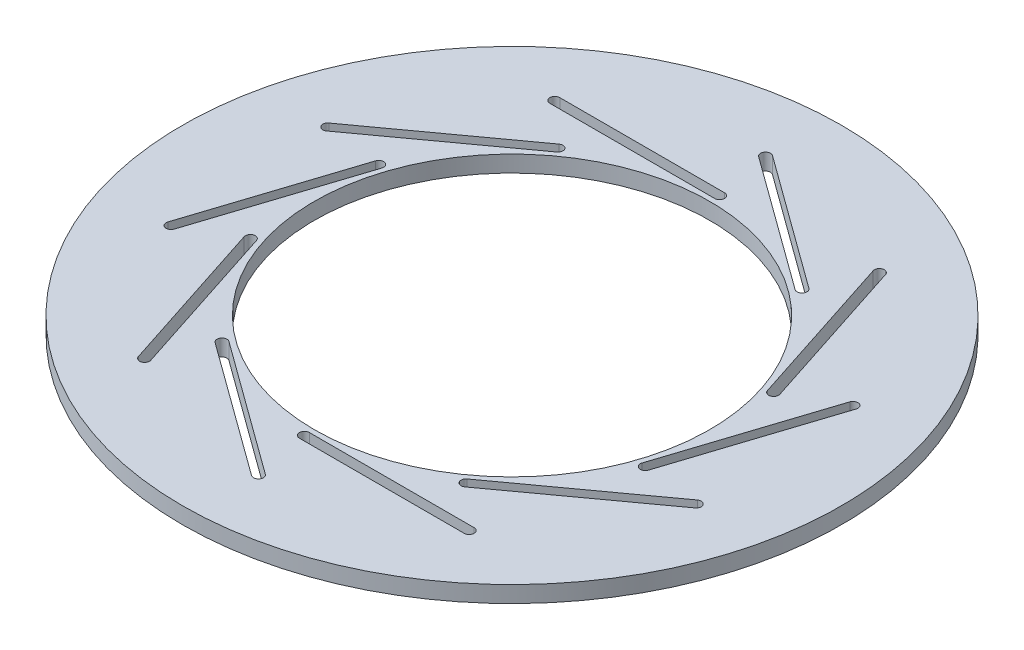
from build123d import *

# Parameters (mm, degrees)
SKETCH1_R           = 100
SKETCH1_R_2         = 60
BOSS_EXTRUDE1_DEPTH = 5


with BuildPart() as part:
    # Sketch1 → Boss-Extrude1 (new body)
    with BuildSketch(Plane(origin=(0, 0, 0), x_dir=(1, 0, 0), z_dir=(0, 1, 0))):
        Circle(SKETCH1_R)
        Circle(SKETCH1_R_2, mode=Mode.SUBTRACT)
        with BuildLine():
            Line((0, 61.5), (-50, 61.5))
            ThreePointArc((-50, 61.5), (-51.5, 63), (-50, 64.5))
            Line((-50, 64.5), (0, 64.5))
            ThreePointArc((0, 64.5), (1.5, 63), (0, 61.5))
        make_face(mode=Mode.SUBTRACT)
        with BuildLine():
            Line((36.148793016, 49.754545154), (-4.302056703, 79.143807769))
            ThreePointArc((-4.302056703, 79.143807769), (-4.633904316, 81.239011139), (-2.538700946, 81.570858752))
            Line((-2.538700946, 81.570858752), (37.912148773, 52.181596137))
            ThreePointArc((37.912148773, 52.181596137), (38.243996386, 50.086392767), (36.148793016, 49.754545154))
        make_face(mode=Mode.SUBTRACT)
        with BuildLine():
            Line((58.489975752, 19.004545154), (43.039126033, 66.557370969))
            ThreePointArc((43.039126033, 66.557370969), (44.002185316, 68.447481235), (45.892295582, 67.484421952))
            Line((45.892295582, 67.484421952), (61.343145301, 19.931596137))
            ThreePointArc((61.343145301, 19.931596137), (60.380086018, 18.041485871), (58.489975752, 19.004545154))
        make_face(mode=Mode.SUBTRACT)
        with BuildLine():
            Line((58.489975752, -19.004545154), (73.940825471, 28.548280661))
            ThreePointArc((73.940825471, 28.548280661), (75.830935737, 29.511339944), (76.79399502, 27.621229678))
            Line((76.79399502, 27.621229678), (61.343145301, -19.931596137))
            ThreePointArc((61.343145301, -19.931596137), (59.453035035, -20.89465542), (58.489975752, -19.004545154))
        make_face(mode=Mode.SUBTRACT)
        with BuildLine():
            Line((36.148793016, -49.754545154), (76.599642735, -20.365282539))
            ThreePointArc((76.599642735, -20.365282539), (78.694846105, -20.697130153), (78.362998492, -22.792333523))
            Line((78.362998492, -22.792333523), (37.912148773, -52.181596137))
            ThreePointArc((37.912148773, -52.181596137), (35.816945403, -51.849748524), (36.148793016, -49.754545154))
        make_face(mode=Mode.SUBTRACT)
        with BuildLine():
            Line((0, -61.5), (50, -61.5))
            ThreePointArc((50, -61.5), (51.5, -63), (50, -64.5))
            Line((50, -64.5), (0, -64.5))
            ThreePointArc((0, -64.5), (-1.5, -63), (0, -61.5))
        make_face(mode=Mode.SUBTRACT)
        with BuildLine():
            Line((-36.148793016, -49.754545154), (4.302056703, -79.143807769))
            ThreePointArc((4.302056703, -79.143807769), (4.633904316, -81.239011139), (2.538700946, -81.570858752))
            Line((2.538700946, -81.570858752), (-37.912148773, -52.181596137))
            ThreePointArc((-37.912148773, -52.181596137), (-38.243996386, -50.086392767), (-36.148793016, -49.754545154))
        make_face(mode=Mode.SUBTRACT)
        with BuildLine():
            Line((-58.489975752, -19.004545154), (-43.039126033, -66.557370969))
            ThreePointArc((-43.039126033, -66.557370969), (-44.002185316, -68.447481235), (-45.892295582, -67.484421952))
            Line((-45.892295582, -67.484421952), (-61.343145301, -19.931596137))
            ThreePointArc((-61.343145301, -19.931596137), (-60.380086018, -18.041485871), (-58.489975752, -19.004545154))
        make_face(mode=Mode.SUBTRACT)
        with BuildLine():
            Line((-58.489975752, 19.004545154), (-73.940825471, -28.548280661))
            ThreePointArc((-73.940825471, -28.548280661), (-75.830935737, -29.511339944), (-76.79399502, -27.621229678))
            Line((-76.79399502, -27.621229678), (-61.343145301, 19.931596137))
            ThreePointArc((-61.343145301, 19.931596137), (-59.453035035, 20.89465542), (-58.489975752, 19.004545154))
        make_face(mode=Mode.SUBTRACT)
        with BuildLine():
            Line((-36.148793016, 49.754545154), (-76.599642735, 20.365282539))
            ThreePointArc((-76.599642735, 20.365282539), (-78.694846105, 20.697130153), (-78.362998492, 22.792333523))
            Line((-78.362998492, 22.792333523), (-37.912148773, 52.181596137))
            ThreePointArc((-37.912148773, 52.181596137), (-35.816945403, 51.849748524), (-36.148793016, 49.754545154))
        make_face(mode=Mode.SUBTRACT)
    extrude(amount=BOSS_EXTRUDE1_DEPTH)


solid = part.part
